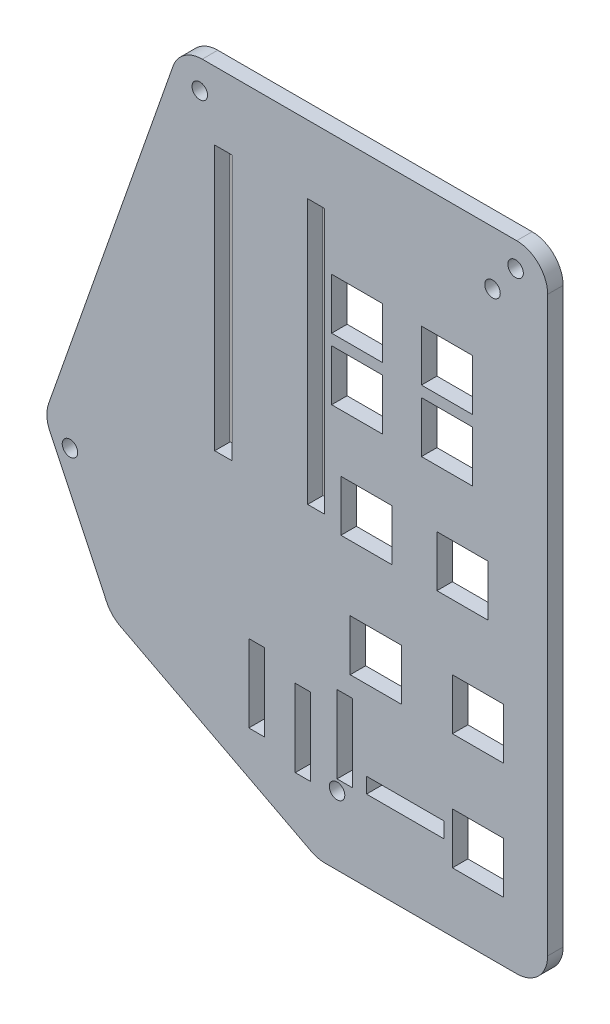
from build123d import *

# Parameters (mm, degrees)
SKETCH1_R           = 1.27
BOSS_EXTRUDE1_DEPTH = 2.54
SKETCH5_W           = 8.382
SKETCH5_H           = 8.382
SKETCH5_W_2         = 2.794
SKETCH5_H_2         = 43.434
CUT_EXTRUDE1_DEPTH  = 3.54
SKETCH7_R           = 1.27
CUT_EXTRUDE3_DEPTH  = 3.54
SKETCH8_W           = 12.7
SKETCH8_H           = 2.54
SKETCH8_W_2         = 2.54
SKETCH8_H_2         = 12.7
CUT_EXTRUDE4_DEPTH  = 3.54


with BuildPart() as part:
    # Sketch1 → Boss-Extrude1 (new body)
    with BuildSketch(Plane.XY):
        with BuildLine():
            Line((-3.314058103, 6.35), (48.26, 6.35))
            ThreePointArc((48.26, 6.35), (51.852102448, 4.862102448), (53.34, 1.27))
            Line((53.34, 1.27), (53.34, -92.71))
            ThreePointArc((53.34, -92.71), (51.852102448, -96.302102448), (48.26, -97.79))
            Line((48.26, -97.79), (16.846989059, -97.79))
            ThreePointArc((16.846989059, -97.79), (15.638688158, -97.644208035), (14.499741809, -97.215200367))
            Line((14.499741809, -97.215200367), (-16.7505185, -80.933552139))
            ThreePointArc((-16.7505185, -80.933552139), (-18.059258376, -79.955412607), (-18.989802686, -78.61241436))
            Line((-18.989802686, -78.61241436), (-28.309569459, -59.040904135))
            ThreePointArc((-28.309569459, -59.040904135), (-28.795802898, -57.127870198), (-28.51617555, -55.173917704))
            Line((-28.51617555, -55.173917704), (-8.107195629, 2.952923842))
            ThreePointArc((-8.107195629, 2.952923842), (-6.251501454, 5.414614163), (-3.314058103, 6.35))
        make_face()
        with Locations((48.0822, 2.286)):
            Circle(SKETCH1_R, mode=Mode.SUBTRACT)
        with Locations((-3.718687848, 1.651)):
            Circle(SKETCH1_R, mode=Mode.SUBTRACT)
        with Locations((-25.012261453, -59.761967182)):
            Circle(SKETCH1_R, mode=Mode.SUBTRACT)
    extrude(amount=BOSS_EXTRUDE1_DEPTH)

    # Sketch5 → Cut-Extrude1 (cut, through all)
    with BuildSketch(Plane(origin=(0, 0, 0), x_dir=(-1, 0, 0), z_dir=(0, 0, -1))):
        with Locations((-36.83, -17.78)):
            Rectangle(SKETCH5_W, SKETCH5_H)
        with Locations((-39.37, -45.72)):
            Rectangle(SKETCH5_W, SKETCH5_H)
        with Locations((-36.83, -27.94)):
            Rectangle(SKETCH5_W, SKETCH5_H)
        with Locations((-41.91, -64.77)):
            Rectangle(SKETCH5_W, SKETCH5_H)
        with Locations((-41.91, -83.82)):
            Rectangle(SKETCH5_W, SKETCH5_H)
        with Locations((-22.098, -17.78)):
            Rectangle(SKETCH5_W, SKETCH5_H)
        with Locations((-22.098, -27.94)):
            Rectangle(SKETCH5_W, SKETCH5_H)
        with Locations((-23.622, -45.72)):
            Rectangle(SKETCH5_W, SKETCH5_H)
        with Locations((-25.146, -64.77)):
            Rectangle(SKETCH5_W, SKETCH5_H)
        with Locations((-15.367, -26.543)):
            Rectangle(SKETCH5_W_2, SKETCH5_H_2)
        with Locations((-0.127, -26.543)):
            Rectangle(SKETCH5_W_2, SKETCH5_H_2)
    extrude(amount=-CUT_EXTRUDE1_DEPTH, mode=Mode.SUBTRACT)

    # Sketch7 → Cut-Extrude3 (cut, through all)
    with BuildSketch(Plane.XY.offset(2.54)):
        with Locations((44.2976, -2.4892)):
            Circle(SKETCH7_R)
        with Locations((18.796, -86.5378)):
            Circle(SKETCH7_R)
    extrude(amount=-CUT_EXTRUDE3_DEPTH, mode=Mode.SUBTRACT)

    # Sketch8 → Cut-Extrude4 (cut, through all)
    with BuildSketch(Plane.XY.offset(2.54)):
        with Locations((29.972, -83.312)):
            Rectangle(SKETCH8_W, SKETCH8_H)
        with Locations((20.066, -78.486)):
            Rectangle(SKETCH8_W_2, SKETCH8_H_2)
        with Locations((13.208, -81.026)):
            Rectangle(SKETCH8_W_2, SKETCH8_H_2)
        with Locations((5.588, -78.486)):
            Rectangle(SKETCH8_W_2, SKETCH8_H_2)
    extrude(amount=-CUT_EXTRUDE4_DEPTH, mode=Mode.SUBTRACT)


solid = part.part
